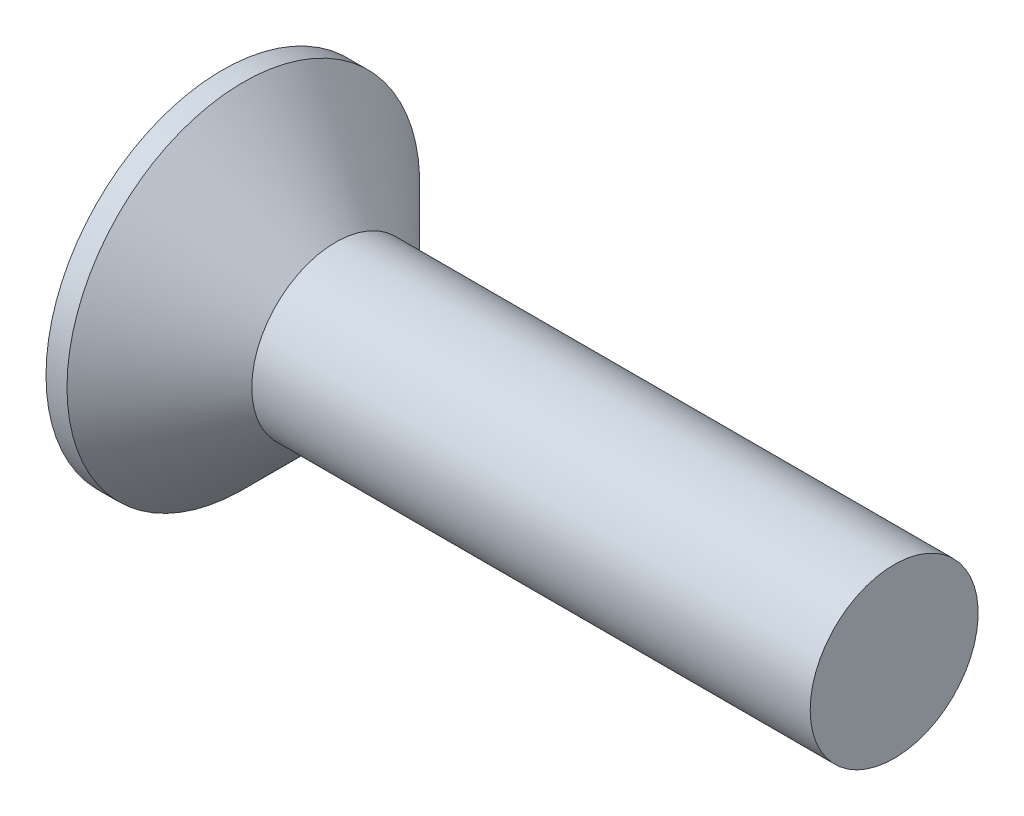
from build123d import *

# Parameters (mm, degrees)
SKETCH3_W         = 0.96
SKETCH3_H         = 4.46
SKETCH4_W         = 0.48
SKETCH4_H         = 0.48
CIRPATTERN1_COUNT = 2
CIRPATTERN1_ANGLE = 90


with BuildPart() as part:
    # BodySke → Base-Revolve (revolve)
    with BuildSketch(Plane.XY):
        Polygon((0, 0), (0, 4.2), (0.5, 4.2), (2.7, 2), (16, 2), (16, 0), align=None)
    revolve(axis=Axis((-6.35, 0, 0), (1, 0, 0)))

    # Sketch3 → Cross section 0
    with BuildSketch(Plane.ZY):
        Rectangle(SKETCH3_W, SKETCH3_H)
    # Sketch4 → Cross section 1
    with BuildSketch(Plane.ZY.offset(-2.65)):
        Rectangle(SKETCH4_W, SKETCH4_H)
    cross = loft(mode=Mode.SUBTRACT)

    # CirPattern1: Cross ×2 about axis
    cirpattern1_axis = Axis((0, 0, 0), (1, 0, 0))
    for i in range(1, CIRPATTERN1_COUNT):
        add(cross.rotate(cirpattern1_axis, i * CIRPATTERN1_ANGLE / (CIRPATTERN1_COUNT - 1)), mode=Mode.SUBTRACT)


solid = part.part
